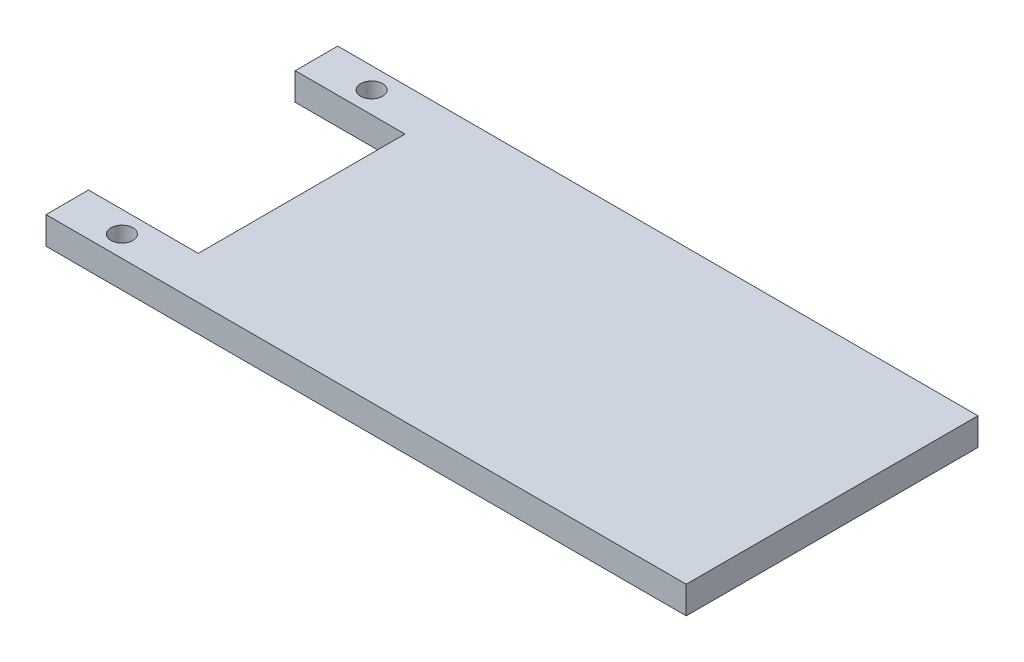
from build123d import *

# Parameters (mm, degrees)
SKETCH1_W           = 70
SKETCH1_H           = 31.9
BOSS_EXTRUDE1_DEPTH = 3
SKETCH2_R           = 1.2
CUT_EXTRUDE1_DEPTH  = 3
SKETCH3_W           = 24
SKETCH3_H           = 22.6
CUT_EXTRUDE2_DEPTH  = 3


with BuildPart() as part:
    # Sketch1 → Boss-Extrude1 (new body)
    with BuildSketch(Plane(origin=(0, 0, 0), x_dir=(1, 0, 0), z_dir=(0, 1, 0))):
        Rectangle(SKETCH1_W, SKETCH1_H)
    extrude(amount=BOSS_EXTRUDE1_DEPTH)

    # Sketch2 → Cut-Extrude1 (cut)
    with BuildSketch(Plane(origin=(0, 3, 0), x_dir=(1, 0, 0), z_dir=(0, 1, 0))):
        with Locations((-29, 13.65)):
            Circle(SKETCH2_R)
    cut_extrude1 = extrude(amount=-CUT_EXTRUDE1_DEPTH, mode=Mode.SUBTRACT)

    # Mirror1: Cut-Extrude1 across plane
    add(cut_extrude1.mirror(Plane.XY), mode=Mode.SUBTRACT)

    # Sketch3 → Cut-Extrude2 (cut)
    with BuildSketch(Plane(origin=(0, 3, 0), x_dir=(1, 0, 0), z_dir=(0, 1, 0))):
        with Locations((-35, 0)):
            Rectangle(SKETCH3_W, SKETCH3_H)
    extrude(amount=-CUT_EXTRUDE2_DEPTH, mode=Mode.SUBTRACT)


solid = part.part
